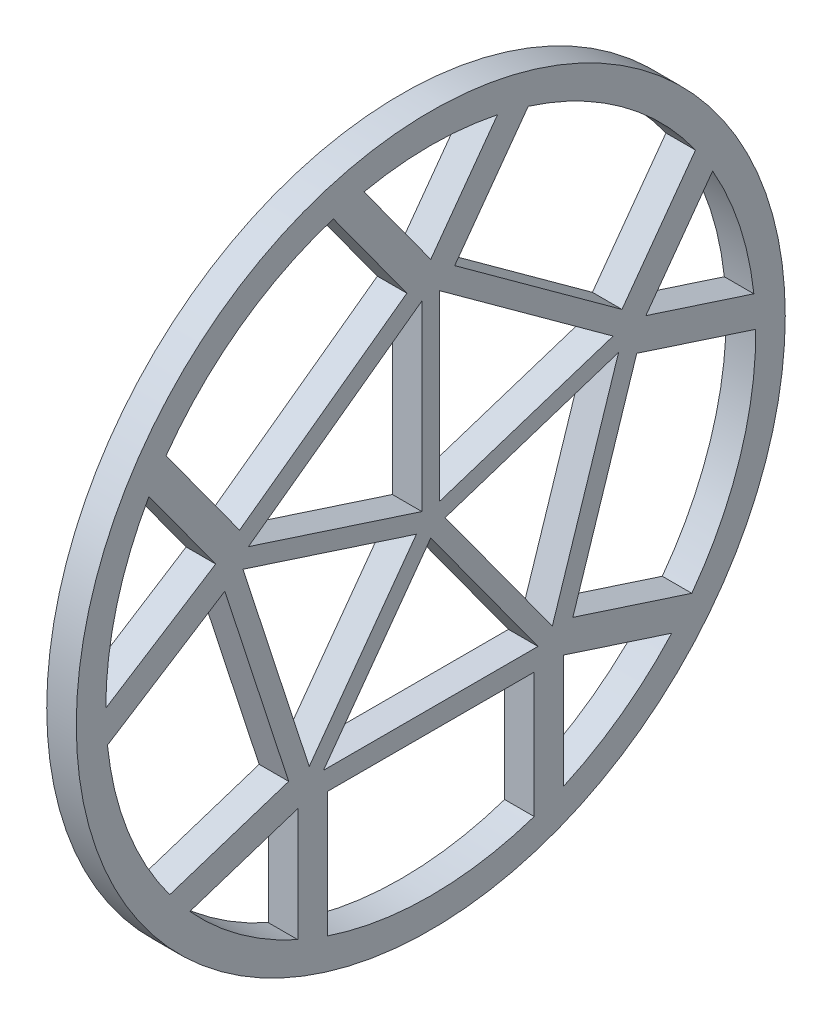
from build123d import *

# Parameters (mm, degrees)
SKETCH2_R           = 60
BOSS_EXTRUDE2_DEPTH = 5


with BuildPart() as part:
    # Sketch2 → Boss-Extrude2 (new body)
    with BuildSketch(Plane(origin=(0, 0, 0), x_dir=(0, 0, -1), z_dir=(1, 0, 0))):
        Circle(SKETCH2_R)
        with BuildLine():
            Line((-32.360679775, 14.767876284), (-44.805880919, 31.897226135))
            ThreePointArc((-44.805880919, 31.897226135), (-32.328188876, 44.495934691), (-16.490286116, 52.469709965))
            Line((-16.490286116, 52.469709965), (-4.045084972, 35.340360114))
            Line((-4.045084972, 35.340360114), (-32.360679775, 14.767876284))
        make_face(mode=Mode.SUBTRACT)
        with BuildLine():
            Line((-47.702148851, 27.37708887), (-36.405764747, 11.828950023))
            Line((-36.405764747, 11.828950023), (-55, 0))
            ThreePointArc((-55, 0), (-53.144229164, 14.166541801), (-47.702148851, 27.37708887))
        make_face(mode=Mode.SUBTRACT)
        with BuildLine():
            Line((0, 38.279286376), (-11.296384104, 53.827425223))
            ThreePointArc((-11.296384104, 53.827425223), (0, 55), (11.296384104, 53.827425223))
            Line((11.296384104, 53.827425223), (0, 38.279286376))
        make_face(mode=Mode.SUBTRACT)
        with BuildLine():
            Line((-54.718344288, -5.559028547), (-34.860679775, 7.073667441))
            Line((-34.860679775, 7.073667441), (-24.045084972, -26.213310629))
            Line((-24.045084972, -26.213310629), (-44.181843419, -32.756140067))
            ThreePointArc((-44.181843419, -32.756140067), (-51.285792388, -19.868756859), (-54.718344288, -5.559028547))
        make_face(mode=Mode.SUBTRACT)
        with BuildLine():
            Line((4.045084972, 35.340360114), (16.490286116, 52.469709965))
            ThreePointArc((16.490286116, 52.469709965), (32.328188876, 44.495934691), (44.805880919, 31.897226135))
            Line((44.805880919, 31.897226135), (32.360679775, 14.767876284))
            Line((32.360679775, 14.767876284), (4.045084972, 35.340360114))
        make_face(mode=Mode.SUBTRACT)
        with BuildLine():
            Line((-40.77793343, -36.907453789), (-22.5, -30.968593211))
            Line((-22.5, -30.968593211), (-22.5, -50.18714975))
            ThreePointArc((-22.5, -50.18714975), (-32.328188876, -44.495934691), (-40.77793343, -36.907453789))
        make_face(mode=Mode.SUBTRACT)
        with BuildLine():
            Line((36.405764747, 11.828950023), (47.702148851, 27.37708887))
            ThreePointArc((47.702148851, 27.37708887), (52.308108396, 16.995934691), (54.683698177, 5.890089445))
            Line((54.683698177, 5.890089445), (36.405764747, 11.828950023))
        make_face(mode=Mode.SUBTRACT)
        with BuildLine():
            Line((-17.5, -52.141634037), (-17.5, -30.968593211))
            Line((-17.5, -30.968593211), (17.5, -30.968593211))
            Line((17.5, -30.968593211), (17.5, -52.141634037))
            ThreePointArc((17.5, -52.141634037), (0, -55), (-17.5, -52.141634037))
        make_face(mode=Mode.SUBTRACT)
        with BuildLine():
            Line((34.860679775, 7.073667441), (54.997438222, 0.530838003))
            ThreePointArc((54.997438222, 0.530838003), (52.308108396, -16.995934691), (44.181843419, -32.756140067))
            Line((44.181843419, -32.756140067), (24.045084972, -26.213310629))
            Line((24.045084972, -26.213310629), (34.860679775, 7.073667441))
        make_face(mode=Mode.SUBTRACT)
        with BuildLine():
            Line((22.5, -50.18714975), (22.5, -30.968593211))
            Line((22.5, -30.968593211), (40.77793343, -36.907453789))
            ThreePointArc((40.77793343, -36.907453789), (32.328188876, -44.495934691), (22.5, -50.18714975))
        make_face(mode=Mode.SUBTRACT)
        Polygon((-20.572949017, -25.764282653), (-31.787730758, 8.751266486), (-2.427050983, -0.788596668), align=None, mode=Mode.SUBTRACT)
        Polygon((18.145898034, -27.527638409), (-18.145898034, -27.527638409), (0, -2.551952425), align=None, mode=Mode.SUBTRACT)
        Polygon((31.787730758, 8.751266486), (20.572949017, -25.764282653), (2.427050983, -0.788596668), align=None, mode=Mode.SUBTRACT)
        Polygon((-30.860679775, 11.604436034), (-1.5, 32.936218542), (-1.5, 2.064572881), align=None, mode=Mode.SUBTRACT)
        Polygon((1.5, 32.936218542), (30.860679775, 11.604436034), (1.5, 2.064572881), align=None, mode=Mode.SUBTRACT)
    extrude(amount=BOSS_EXTRUDE2_DEPTH)


solid = part.part
